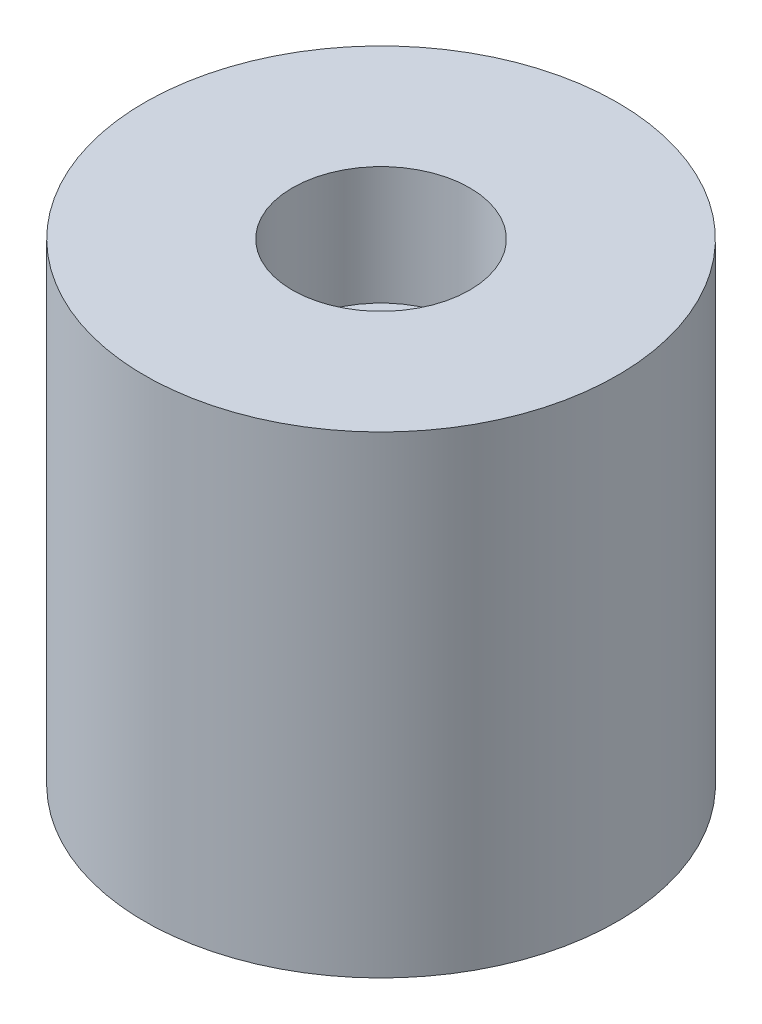
from build123d import *


with BuildPart() as part:
    # Sketch2 → Revolve1 (revolve)
    with BuildSketch(Plane.XY):
        Polygon((1.984375, 6.35), (1.984375, -12.7), (12.7, -12.7), (12.7, 12.7), (4.7625, 12.7), (4.7625, 6.35), align=None)
    revolve(axis=Axis((0, 0, 0), (0, 1, 0)))


solid = part.part
